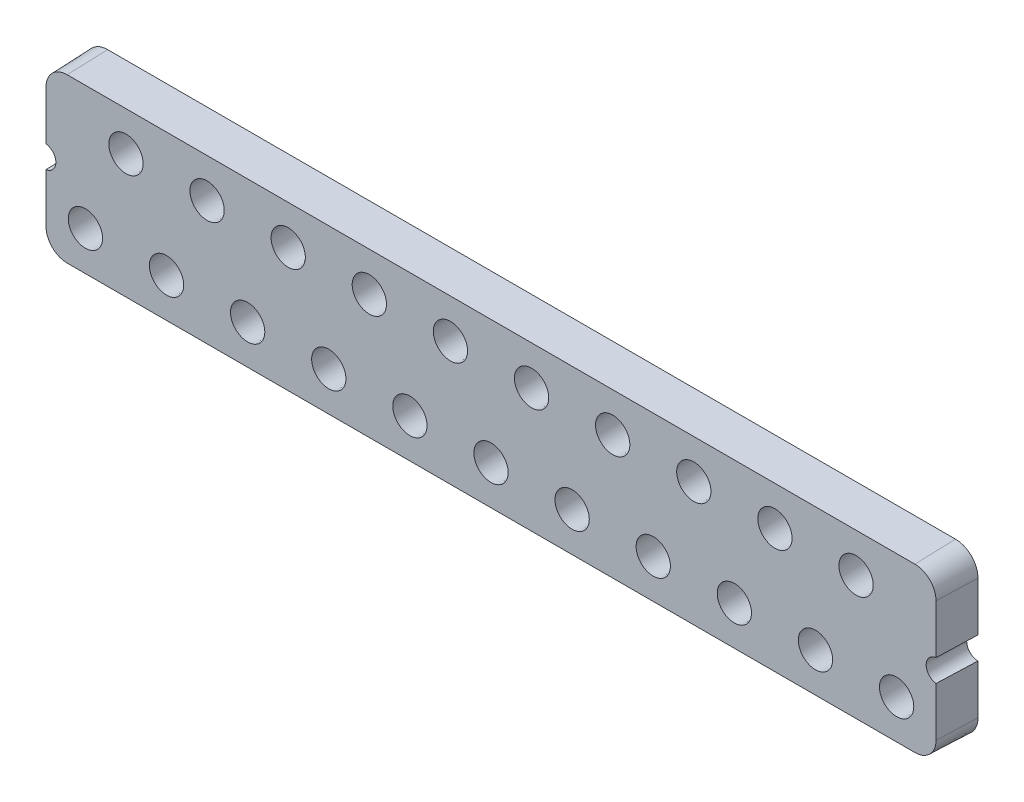
from build123d import *

# Parameters (mm, degrees)
BOSS_EXTRUDE1_DEPTH = 1.8
BOSS_EXTRUDE1_TAPER = 2
SKETCH10_R          = 1.223
CUT_EXTRUDE2_DEPTH  = 0.25
CUT_EXTRUDE2_TAPER  = 2
SKETCH9_R           = 0.815
CUT_EXTRUDE3_DEPTH  = 2.55
CUT_EXTRUDE3_TAPER  = 2
SKETCH12_R          = 0.5
CUT_EXTRUDE4_DEPTH  = 2.8


with BuildPart() as part:
    # Sketch11 → Boss-Extrude1 (new body)
    with BuildSketch(Plane.XY):
        with BuildLine():
            Line((19.812, 0.5), (19.812, 2.683))
            ThreePointArc((19.812, 2.683), (19.519106781, 3.390106781), (18.812, 3.683))
            Line((18.812, 3.683), (-18.812, 3.683))
            ThreePointArc((-18.812, 3.683), (-19.519106781, 3.390106781), (-19.812, 2.683))
            Line((-19.812, 2.683), (-19.812, 0.5))
            Line((-19.812, 0.5), (-19.812, -0.5))
            Line((-19.812, -0.5), (-19.812, -2.683))
            ThreePointArc((-19.812, -2.683), (-19.519106781, -3.390106781), (-18.812, -3.683))
            Line((-18.812, -3.683), (18.812, -3.683))
            ThreePointArc((18.812, -3.683), (19.519106781, -3.390106781), (19.812, -2.683))
            Line((19.812, -2.683), (19.812, -0.5))
            Line((19.812, -0.5), (19.812, 0.5))
        make_face()
    extrude(amount=BOSS_EXTRUDE1_DEPTH, taper=BOSS_EXTRUDE1_TAPER)

    # Sketch10 → Cut-Extrude2 (cut)
    with BuildSketch(Plane.XY):
        with Locations((16.2, 1.885)):
            Circle(SKETCH10_R)
        with Locations((12.6, 1.885)):
            Circle(SKETCH10_R)
        with Locations((9, 1.885)):
            Circle(SKETCH10_R)
        with Locations((5.4, 1.885)):
            Circle(SKETCH10_R)
        with Locations((1.8, 1.885)):
            Circle(SKETCH10_R)
        with Locations((-1.8, 1.885)):
            Circle(SKETCH10_R)
        with Locations((-5.4, 1.885)):
            Circle(SKETCH10_R)
        with Locations((-9, 1.885)):
            Circle(SKETCH10_R)
        with Locations((-12.6, 1.885)):
            Circle(SKETCH10_R)
        with Locations((-16.2, 1.885)):
            Circle(SKETCH10_R)
        with Locations((-18, -1.885)):
            Circle(SKETCH10_R)
        with Locations((-14.4, -1.885)):
            Circle(SKETCH10_R)
        with Locations((-10.8, -1.885)):
            Circle(SKETCH10_R)
        with Locations((-7.2, -1.885)):
            Circle(SKETCH10_R)
        with Locations((-3.6, -1.885)):
            Circle(SKETCH10_R)
        with Locations((0, -1.885)):
            Circle(SKETCH10_R)
        with Locations((3.6, -1.885)):
            Circle(SKETCH10_R)
        with Locations((7.2, -1.885)):
            Circle(SKETCH10_R)
        with Locations((10.8, -1.885)):
            Circle(SKETCH10_R)
        with Locations((14.4, -1.885)):
            Circle(SKETCH10_R)
        with Locations((18, -1.885)):
            Circle(SKETCH10_R)
    extrude(amount=CUT_EXTRUDE2_DEPTH, taper=CUT_EXTRUDE2_TAPER, mode=Mode.SUBTRACT)

    # Sketch9 → Cut-Extrude3 (cut, through all)
    with BuildSketch(Plane.XY.offset(0.25)):
        with Locations((16.2, 1.885)):
            Circle(SKETCH9_R)
        with Locations((12.6, 1.885)):
            Circle(SKETCH9_R)
        with Locations((9, 1.885)):
            Circle(SKETCH9_R)
        with Locations((5.4, 1.885)):
            Circle(SKETCH9_R)
        with Locations((1.8, 1.885)):
            Circle(SKETCH9_R)
        with Locations((-1.8, 1.885)):
            Circle(SKETCH9_R)
        with Locations((-5.4, 1.885)):
            Circle(SKETCH9_R)
        with Locations((-9, 1.885)):
            Circle(SKETCH9_R)
        with Locations((-12.6, 1.885)):
            Circle(SKETCH9_R)
        with Locations((-16.2, 1.885)):
            Circle(SKETCH9_R)
        with Locations((-18, -1.885)):
            Circle(SKETCH9_R)
        with Locations((-14.4, -1.885)):
            Circle(SKETCH9_R)
        with Locations((-10.8, -1.885)):
            Circle(SKETCH9_R)
        with Locations((-7.2, -1.885)):
            Circle(SKETCH9_R)
        with Locations((-3.6, -1.885)):
            Circle(SKETCH9_R)
        with Locations((0, -1.885)):
            Circle(SKETCH9_R)
        with Locations((3.6, -1.885)):
            Circle(SKETCH9_R)
        with Locations((7.2, -1.885)):
            Circle(SKETCH9_R)
        with Locations((10.8, -1.885)):
            Circle(SKETCH9_R)
        with Locations((14.4, -1.885)):
            Circle(SKETCH9_R)
        with Locations((18, -1.885)):
            Circle(SKETCH9_R)
    extrude(amount=CUT_EXTRUDE3_DEPTH, taper=CUT_EXTRUDE3_TAPER, mode=Mode.SUBTRACT)

    # Sketch12 → Cut-Extrude4 (cut, through all)
    with BuildSketch(Plane.XY):
        with Locations((19.812, 0)):
            Circle(SKETCH12_R)
        with Locations((-19.812, 0)):
            Circle(SKETCH12_R)
    extrude(amount=CUT_EXTRUDE4_DEPTH, mode=Mode.SUBTRACT)


solid = part.part
